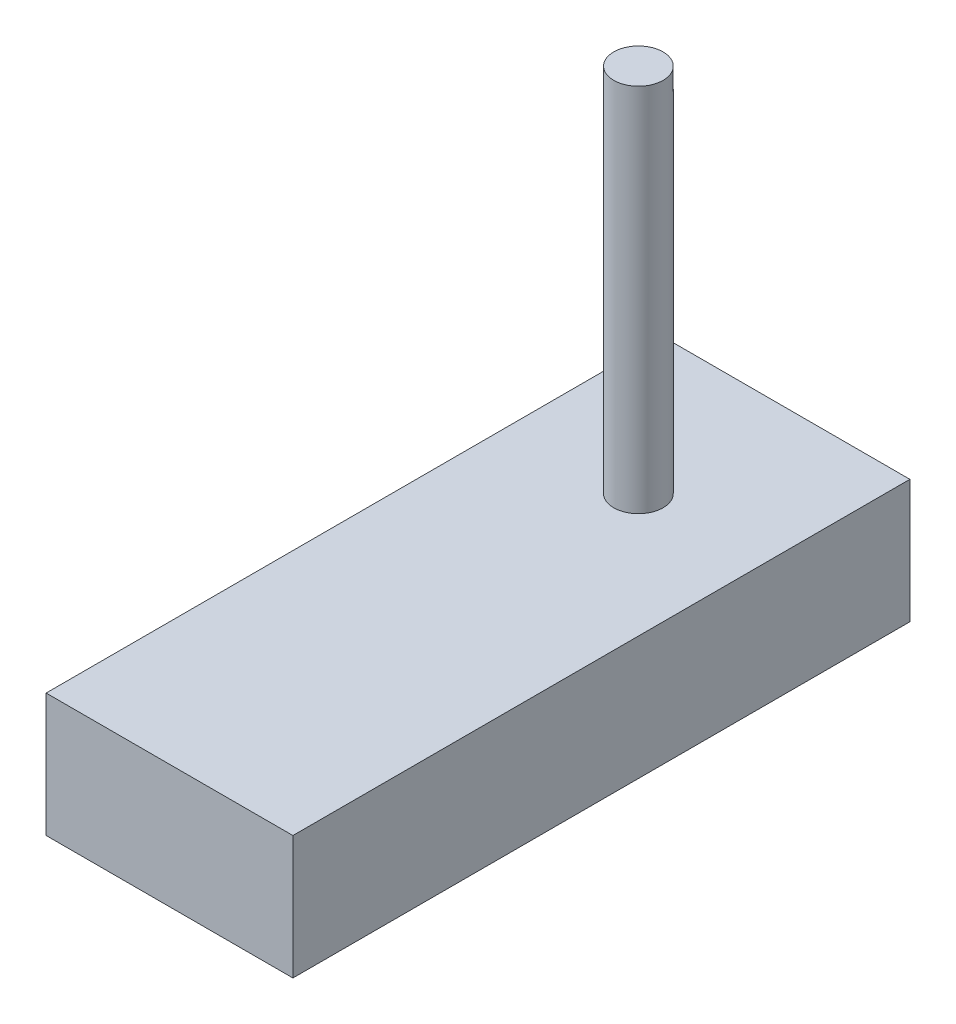
from build123d import *

# Parameters (mm, degrees)
CROQUIS1_W              = 10
CROQUIS1_H              = 25
SALIENTE_EXTRUIR1_DEPTH = 5
CROQUIS2_R              = 1
SALIENTE_EXTRUIR2_DEPTH = 15


with BuildPart() as part:
    # Croquis1 → Saliente-Extruir1 (new body)
    with BuildSketch(Plane(origin=(0, 0, 0), x_dir=(1, 0, 0), z_dir=(0, 1, 0))):
        Rectangle(CROQUIS1_W, CROQUIS1_H)
    extrude(amount=SALIENTE_EXTRUIR1_DEPTH)

    # Croquis2 → Saliente-Extruir2 (add)
    with BuildSketch(Plane(origin=(0, 5, 0), x_dir=(1, 0, 0), z_dir=(0, 1, 0))):
        with Locations((0, 6.5)):
            Circle(CROQUIS2_R)
    extrude(amount=SALIENTE_EXTRUIR2_DEPTH)


solid = part.part
